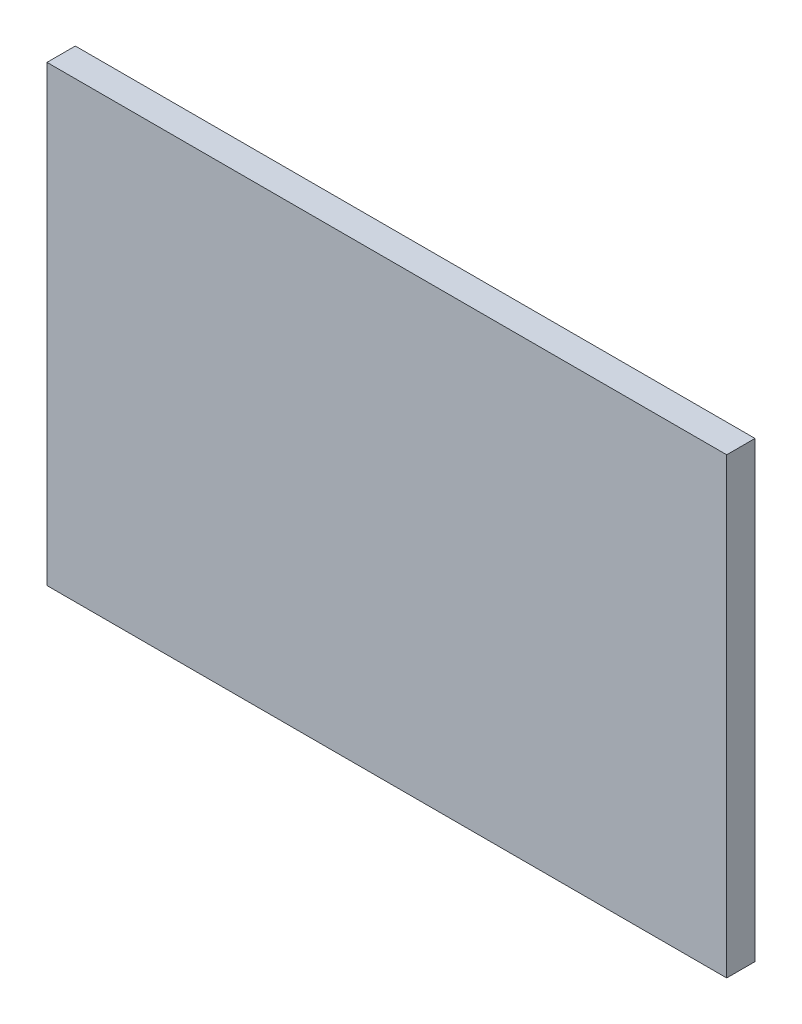
from build123d import *

# Parameters (mm, degrees)
SKETCH1_W           = 152.4
SKETCH1_H           = 101.6
BOSS_EXTRUDE1_DEPTH = 6.35


with BuildPart() as part:
    # Sketch1 → Boss-Extrude1 (new body)
    with BuildSketch(Plane.XY):
        Rectangle(SKETCH1_W, SKETCH1_H)
    extrude(amount=BOSS_EXTRUDE1_DEPTH)


solid = part.part
